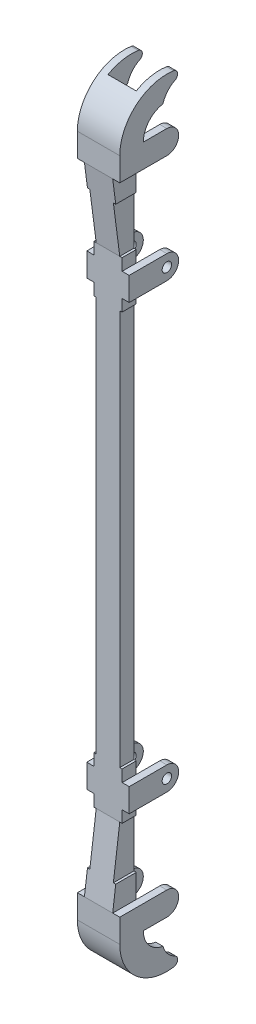
from build123d import *

# Parameters (mm, degrees)
AUFSATZ_LINEAR_START                 = 2.5
SKIZZE2_W                            = 5
SKIZZE2_H                            = 145
AUFSATZ_LINEAR_AUSTRAGEN1_DEPTH      = 3
SKIZZE3_W                            = 3
SKIZZE3_H                            = 10
AUFSATZ_LINEAR_AUSTRAGEN2_DEPTH      = 0.5
AUFSATZ_LINEAR_AUSTRAGEN3_DEPTH      = 1.5
SKIZZE5_R                            = 1
SCHNITT_LINEAR_AUSTRAGEN1_DEPTH      = 10
AUFSATZ_LINEAR_AUSTRAGEN4_DEPTH      = 2
SCHNITT_LINEAR_AUSTRAGEN2_DEPTH      = 5.5
SCHNITT_LINEAR_AUSTRAGEN2_DEPTH_BACK = 5.5
AUFSATZ_LINEAR_AUSTRAGEN6_DEPTH      = 9
SCHNITT_LINEAR_START                 = -39
SKIZZE10_W                           = 6
SKIZZE10_H                           = 10.674676004
SCHNITT_LINEAR_AUSTRAGEN3_DEPTH      = 157
VERRUNDUNG1_R                        = 1
VERRUNDUNG1_OF_SPIEGELN2_R           = 1


with BuildPart() as part:
    # Skizze2 → Aufsatz-Linear austragen1 (new body)
    with BuildSketch(Plane.XY.offset(-2.5).offset(AUFSATZ_LINEAR_START)):
        with Locations((0, -19.833333333)):
            Rectangle(SKIZZE2_W, SKIZZE2_H)
    extrude(amount=AUFSATZ_LINEAR_AUSTRAGEN1_DEPTH)

    # Skizze3 → Aufsatz-Linear austragen2 (add)
    with BuildSketch(Plane(origin=(2.5, 0, 0), x_dir=(0, 0, -1), z_dir=(1, 0, 0))):
        with Locations((-1.5, 27.166666667)):
            Rectangle(SKIZZE3_W, SKIZZE3_H)
        with Locations((-1.5, 47.666666667)):
            Rectangle(SKIZZE3_W, SKIZZE3_H)
        with Locations((-1.5, -66.833333333)):
            Rectangle(SKIZZE3_W, SKIZZE3_H)
        with Locations((-1.5, -87.333333333)):
            Rectangle(SKIZZE3_W, SKIZZE3_H)
    aufsatz_linear_austragen2 = extrude(amount=AUFSATZ_LINEAR_AUSTRAGEN2_DEPTH)

    # Skizze4 → Aufsatz-Linear austragen3 (add)
    with BuildSketch(Plane(origin=(3, 0, 0), x_dir=(0, 0, -1), z_dir=(1, 0, 0))):
        with BuildLine():
            Line((-3, 24.666666667), (-3, 29.666666667))
            Line((-3, 29.666666667), (5, 29.666666667))
            ThreePointArc((5, 29.666666667), (7.5, 27.166666667), (5, 24.666666667))
            Line((5, 24.666666667), (-3, 24.666666667))
        make_face()
        with BuildLine():
            Line((5, -64.333333333), (-3, -64.333333333))
            Line((-3, -64.333333333), (-3, -69.333333333))
            Line((-3, -69.333333333), (5, -69.333333333))
            ThreePointArc((5, -69.333333333), (7.5, -66.833333333), (5, -64.333333333))
        make_face()
        with BuildLine():
            Line((5, 52.666666667), (-3, 52.666666667))
            Line((-3, 52.666666667), (-3, 47.666666667))
            Line((-3, 47.666666667), (5, 47.666666667))
            ThreePointArc((5, 47.666666667), (7.5, 50.166666667), (5, 52.666666667))
        make_face()
        with BuildLine():
            Line((-3, -92.333333333), (-3, -87.333333333))
            Line((-3, -87.333333333), (5, -87.333333333))
            ThreePointArc((5, -87.333333333), (7.5, -89.833333333), (5, -92.333333333))
            Line((5, -92.333333333), (-3, -92.333333333))
        make_face()
    aufsatz_linear_austragen3 = extrude(amount=AUFSATZ_LINEAR_AUSTRAGEN3_DEPTH)

    # Spiegeln1: Aufsatz-Linear austragen2, Aufsatz-Linear austragen3 across plane
    add(aufsatz_linear_austragen2.mirror(Plane(origin=(0, 0, 0), x_dir=(0, 0, 1), z_dir=(1, 0, 0))))
    add(aufsatz_linear_austragen3.mirror(Plane(origin=(0, 0, 0), x_dir=(0, 0, 1), z_dir=(1, 0, 0))))

    # Skizze5 → Schnitt-Linear austragen1 (cut, through all)
    with BuildSketch(Plane(origin=(4.5, 0, 0), x_dir=(0, 0, -1), z_dir=(1, 0, 0))):
        with Locations((5, 27.166666667)):
            Circle(SKIZZE5_R)
        with Locations((5, -66.833333333)):
            Circle(SKIZZE5_R)
    extrude(amount=-SCHNITT_LINEAR_AUSTRAGEN1_DEPTH, mode=Mode.SUBTRACT)

    # Skizze6 → Aufsatz-Linear austragen4 (add)
    with BuildSketch(Plane.XY.offset(3)):
        Polygon((-4.5, 52.666666667), (-4.5, 47.666666667), (-3, 47.666666667), (-3, 42.666666667), (-2.5, 42.666666667), (-2.5, 32.166666667), (2.5, 32.166666667), (2.5, 42.666666667), (3, 42.666666667), (3, 47.666666667), (4.5, 47.666666667), (4.5, 52.666666667), align=None)
        Polygon((4.5, -92.333333333), (-4.5, -92.333333333), (-4.5, -87.333333333), (-3, -87.333333333), (-3, -82.333333333), (-2.5, -82.333333333), (-2.5, -71.833333333), (2.5, -71.833333333), (2.5, -82.333333333), (3, -82.333333333), (3, -87.333333333), (4.5, -87.333333333), align=None)
    extrude(amount=AUFSATZ_LINEAR_AUSTRAGEN4_DEPTH)

    # Skizze7 → Schnitt-Linear austragen2 (cut, two sides)
    with BuildSketch(Plane(origin=(0, 0, 0), x_dir=(0, 0, -1), z_dir=(1, 0, 0))) as schnitt_linear_austragen2_sk:
        Polygon((-3, 32.166666667), (-5, 47.666666667), (-5, 32.166666667), align=None)
        Polygon((-5, -71.833333333), (-3, -71.833333333), (-5, -87.333333333), align=None)
    extrude(amount=SCHNITT_LINEAR_AUSTRAGEN2_DEPTH, mode=Mode.SUBTRACT)
    extrude(schnitt_linear_austragen2_sk.sketch, amount=-SCHNITT_LINEAR_AUSTRAGEN2_DEPTH_BACK, mode=Mode.SUBTRACT)

    # Skizze9 → Aufsatz-Linear austragen6 (add)
    with BuildSketch(Plane(origin=(4.5, 0, 0), x_dir=(0, 0, -1), z_dir=(1, 0, 0))):
        with BuildLine():
            Line((0, -92.333333333), (-5, -92.333333333))
            ThreePointArc((-5, -92.333333333), (0.349557013, -101.186207444), (10.674676004, -100.567290598))
            ThreePointArc((10.674676004, -100.567290598), (6.701834217, -100.327622333), (4.162678595, -97.262724053))
            ThreePointArc((4.162678595, -97.262724053), (1.179881741, -95.559274512), (0, -92.333333333))
        make_face()
    aufsatz_linear_austragen6 = extrude(amount=-AUFSATZ_LINEAR_AUSTRAGEN6_DEPTH)

    # Skizze10 → Schnitt-Linear austragen3 (cut)
    with BuildSketch(Plane(origin=(0, -64.333333333, 0), x_dir=(1, 0, 0), z_dir=(0, 1, 0)).offset(SCHNITT_LINEAR_START)):
        with Locations((0, 5.337338002)):
            Rectangle(SKIZZE10_W, SKIZZE10_H)
    schnitt_linear_austragen3 = extrude(amount=SCHNITT_LINEAR_AUSTRAGEN3_DEPTH, mode=Mode.SUBTRACT)

    # Verrundung1
    verrundung1_edges = [part.edges().sort_by_distance(p)[0] for p in [
        (-3.75, -100.567290598, -10.674676004),
        (3.75, -100.567290598, -10.674676004),
    ]]
    fillet(verrundung1_edges, radius=VERRUNDUNG1_R)

    # Spiegeln2: Aufsatz-Linear austragen6, Schnitt-Linear austragen3 across plane
    add(aufsatz_linear_austragen6.mirror(Plane(origin=(0, -19.833333333, 0), x_dir=(0, 0, 1), z_dir=(0, -1, 0))))
    add(schnitt_linear_austragen3.mirror(Plane(origin=(0, -19.833333333, 0), x_dir=(0, 0, 1), z_dir=(0, -1, 0))), mode=Mode.SUBTRACT)

    # Verrundung1 of Spiegeln2
    verrundung1_of_spiegeln2_edges = [part.edges().sort_by_distance(p)[0] for p in [
        (-3.75, 60.900623932, -10.674676004),
        (3.75, 60.900623932, -10.674676004),
    ]]
    fillet(verrundung1_of_spiegeln2_edges, radius=VERRUNDUNG1_OF_SPIEGELN2_R)


solid = part.part
